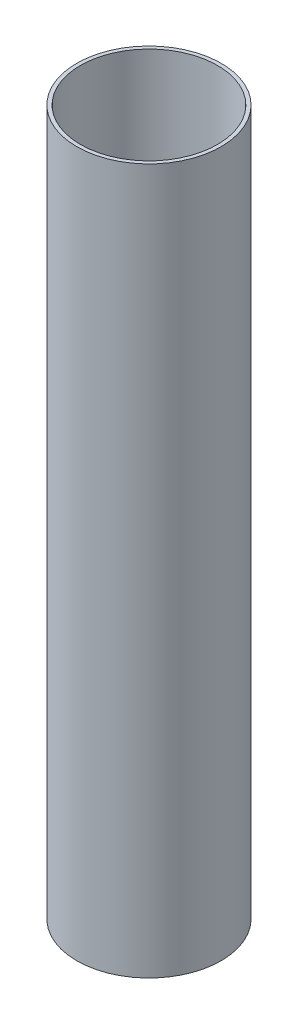
from build123d import *

# Parameters (mm, degrees)
SKETCH1_R           = 93.6625
SKETCH1_R_2         = 88.9
BOSS_EXTRUDE1_DEPTH = 457.2


with BuildPart() as part:
    # Sketch1 → Boss-Extrude1 (new body, symmetric)
    with BuildSketch(Plane(origin=(0, 0, 0), x_dir=(1, 0, 0), z_dir=(0, 1, 0))):
        Circle(SKETCH1_R)
        Circle(SKETCH1_R_2, mode=Mode.SUBTRACT)
    extrude(amount=BOSS_EXTRUDE1_DEPTH, both=True)


solid = part.part
